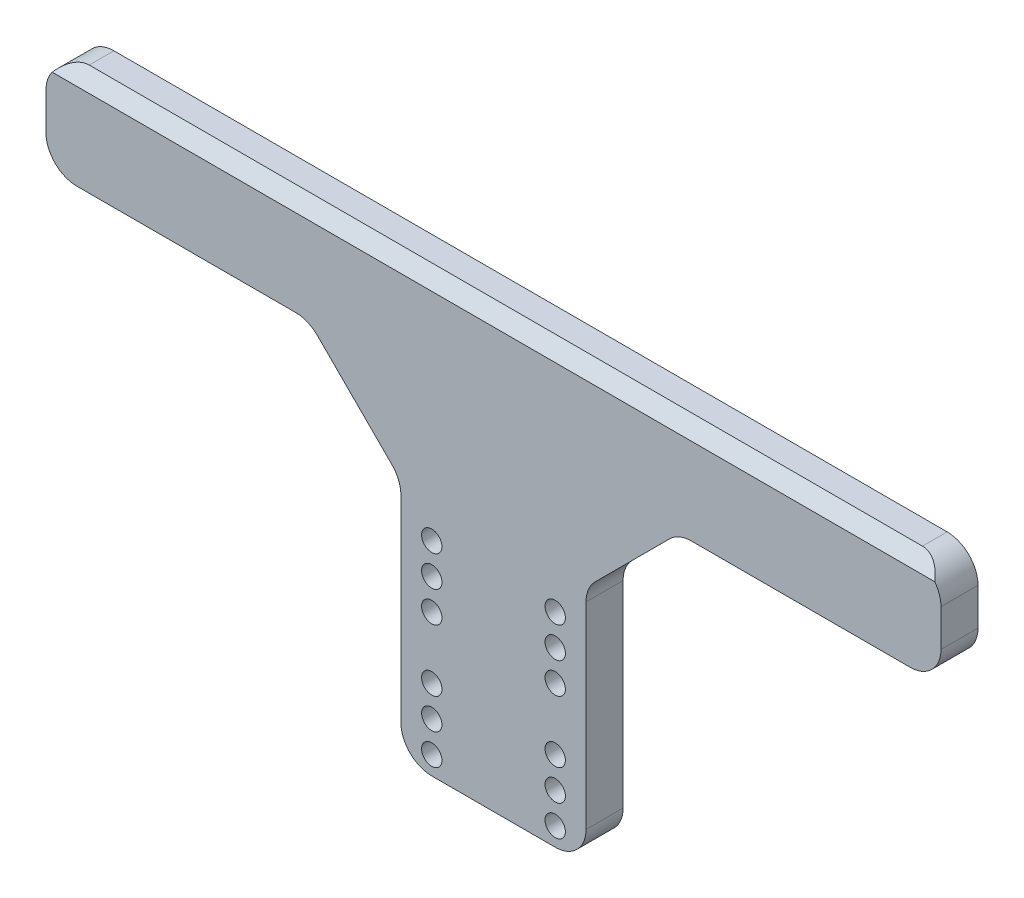
from build123d import *

# Parameters (mm, degrees)
ESQUISSE1_W                  = 145
ESQUISSE1_H                  = 40
BOSS_EXTRU_1_DEPTH           = 6
ESQUISSE2_R                  = 1.65
ENL_V_MAT_EXTRU_1_DEPTH      = 1
ENL_V_MAT_EXTRU_1_DEPTH_BACK = 7
ESQUISSE3_W                  = 145
ESQUISSE3_H                  = 30
BOSS_EXTRU_2_DEPTH           = 6
CHANFREIN1_SIZE              = 2
ESQUISSE4_W                  = 57.5
ESQUISSE4_H                  = 54
ENL_V_MAT_EXTRU_2_DEPTH      = 1
ENL_V_MAT_EXTRU_2_DEPTH_BACK = 7
CHANFREIN2_SIZE              = 15
CONG_2_R                     = 5


with BuildPart() as part:
    # Esquisse1 → Boss.-Extru.1 (new body)
    with BuildSketch(Plane.XY):
        with Locations((72.5, 20)):
            Rectangle(ESQUISSE1_W, ESQUISSE1_H)
    extrude(amount=BOSS_EXTRU_1_DEPTH)

    # Esquisse2 → Enlèv. mat.-Extru.1 (cut, two sides)
    with BuildSketch(Plane.XY.offset(6)) as enl_v_mat_extru_1_sk:
        with Locations((62.5, 23)):
            Circle(ESQUISSE2_R)
        with Locations((62.5, 3)):
            Circle(ESQUISSE2_R)
        with Locations((82.5, 3)):
            Circle(ESQUISSE2_R)
        with Locations((82.5, 23)):
            Circle(ESQUISSE2_R)
        with Locations((62.5, 28)):
            Circle(ESQUISSE2_R)
        with Locations((62.5, 8)):
            Circle(ESQUISSE2_R)
        with Locations((82.5, 8)):
            Circle(ESQUISSE2_R)
        with Locations((82.5, 28)):
            Circle(ESQUISSE2_R)
        with Locations((62.5, 33)):
            Circle(ESQUISSE2_R)
        with Locations((62.5, 13)):
            Circle(ESQUISSE2_R)
        with Locations((82.5, 13)):
            Circle(ESQUISSE2_R)
        with Locations((82.5, 33)):
            Circle(ESQUISSE2_R)
    extrude(amount=ENL_V_MAT_EXTRU_1_DEPTH, mode=Mode.SUBTRACT)
    extrude(enl_v_mat_extru_1_sk.sketch, amount=-ENL_V_MAT_EXTRU_1_DEPTH_BACK, mode=Mode.SUBTRACT)

    # Esquisse3 → Boss.-Extru.2 (add)
    with BuildSketch(Plane.XY.offset(6)):
        with Locations((72.5, 55)):
            Rectangle(ESQUISSE3_W, ESQUISSE3_H)
    extrude(amount=-BOSS_EXTRU_2_DEPTH)

    # Chanfrein1
    chanfrein1_edges = [part.edges().sort_by_distance(p)[0] for p in [
        (72.5, 70, 6),
    ]]
    chamfer(chanfrein1_edges, length=CHANFREIN1_SIZE)

    # Esquisse4 → Enlèv. mat.-Extru.2 (cut, two sides)
    with BuildSketch(Plane.XY.offset(6)) as enl_v_mat_extru_2_sk:
        with Locations((28.75, 27)):
            Rectangle(ESQUISSE4_W, ESQUISSE4_H)
        with Locations((116.25, 27)):
            Rectangle(ESQUISSE4_W, ESQUISSE4_H)
    extrude(amount=ENL_V_MAT_EXTRU_2_DEPTH, mode=Mode.SUBTRACT)
    extrude(enl_v_mat_extru_2_sk.sketch, amount=-ENL_V_MAT_EXTRU_2_DEPTH_BACK, mode=Mode.SUBTRACT)

    # Chanfrein2
    chanfrein2_edges = [part.edges().sort_by_distance(p)[0] for p in [
        (87.5, 54, 3),
        (57.5, 54, 3),
    ]]
    chamfer(chanfrein2_edges, length=CHANFREIN2_SIZE)

    # Congé2
    cong_2_edges = [part.edges().sort_by_distance(p)[0] for p in [
        (145, 70, 2),
        (145, 54, 3),
        (102.5, 54, 3),
        (87.5, 39, 3),
        (87.5, 0, 3),
        (57.5, 0, 3),
        (57.5, 39, 3),
        (42.5, 54, 3),
        (0, 54, 3),
        (0, 70, 2),
    ]]
    fillet(cong_2_edges, radius=CONG_2_R)


solid = part.part
